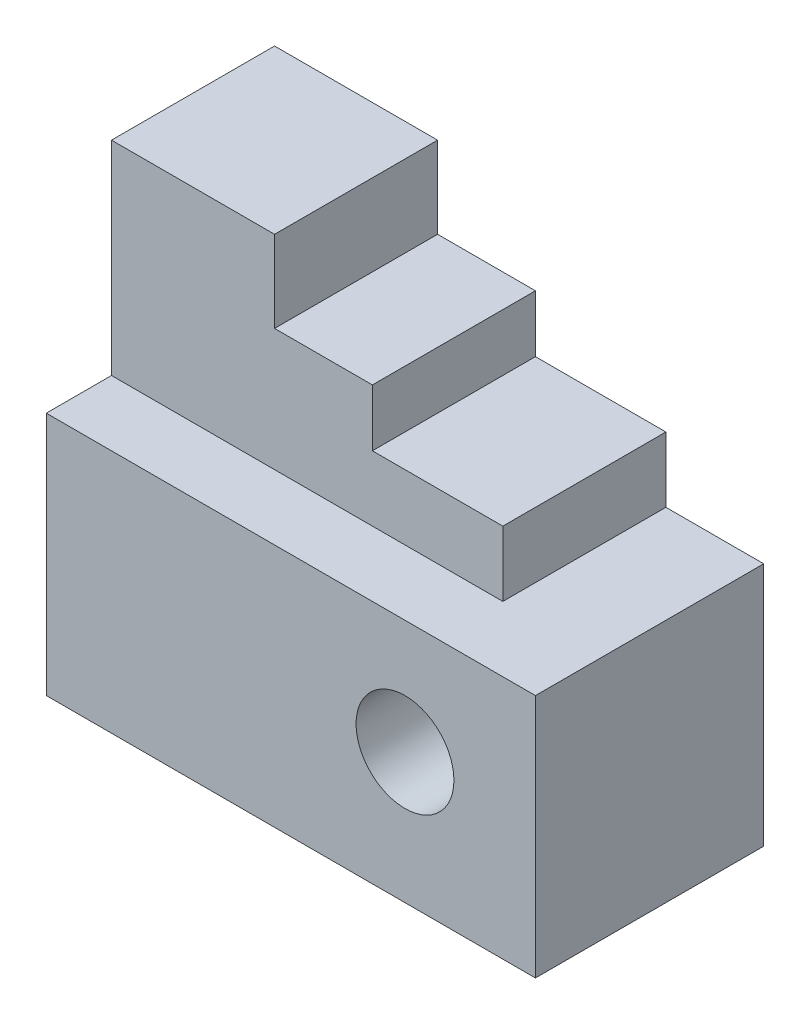
from build123d import *

# Parameters (mm, degrees)
SKETCH1_W           = 60
SKETCH1_H           = 30
BOSS_EXTRUDE1_DEPTH = 28
SKETCH2_R           = 6
CUT_EXTRUDE1_DEPTH  = 28
SKETCH3_W           = 20
SKETCH3_H           = 20
BOSS_EXTRUDE3_DEPTH = 25
SKETCH5_W           = 12
SKETCH5_H           = 20
BOSS_EXTRUDE4_DEPTH = 15
SKETCH8_W           = 16
SKETCH8_H           = 20
BOSS_EXTRUDE5_DEPTH = 8


with BuildPart() as part:
    # Sketch1 → Boss-Extrude1 (new body)
    with BuildSketch(Plane.XY):
        with Locations((30, 15)):
            Rectangle(SKETCH1_W, SKETCH1_H)
    extrude(amount=BOSS_EXTRUDE1_DEPTH)

    # Sketch2 → Cut-Extrude1 (cut)
    with BuildSketch(Plane.XY.offset(28)):
        with Locations((44, 16)):
            Circle(SKETCH2_R)
    extrude(amount=-CUT_EXTRUDE1_DEPTH, mode=Mode.SUBTRACT)

    # Sketch3 → Boss-Extrude3 (add)
    with BuildSketch(Plane(origin=(0, 30, 0), x_dir=(1, 0, 0), z_dir=(0, 1, 0))):
        with Locations((10, -10)):
            Rectangle(SKETCH3_W, SKETCH3_H)
    extrude(amount=BOSS_EXTRUDE3_DEPTH)

    # Sketch5 → Boss-Extrude4 (add)
    with BuildSketch(Plane(origin=(0, 30, 0), x_dir=(1, 0, 0), z_dir=(0, 1, 0))):
        with Locations((26, -10)):
            Rectangle(SKETCH5_W, SKETCH5_H)
    extrude(amount=BOSS_EXTRUDE4_DEPTH)

    # Sketch8 → Boss-Extrude5 (add)
    with BuildSketch(Plane(origin=(0, 30, 0), x_dir=(1, 0, 0), z_dir=(0, 1, 0))):
        with Locations((40, -10)):
            Rectangle(SKETCH8_W, SKETCH8_H)
    extrude(amount=BOSS_EXTRUDE5_DEPTH)


solid = part.part
